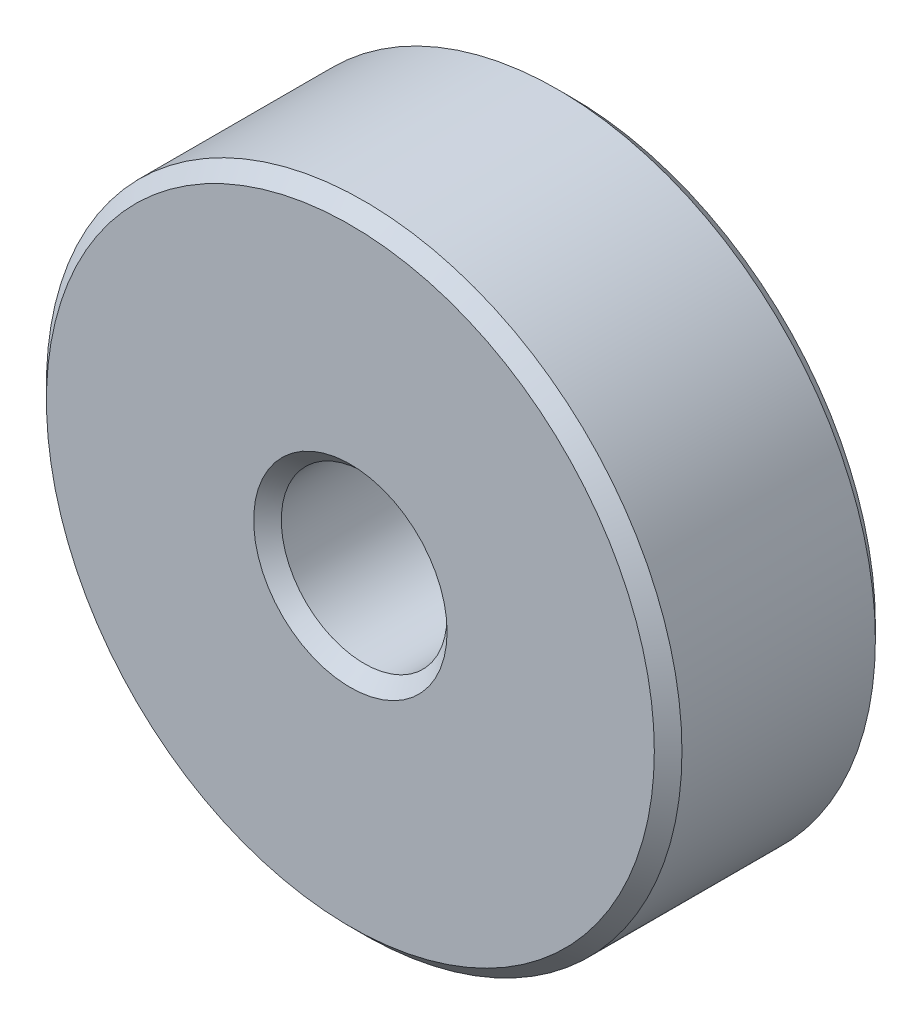
from build123d import *

# Parameters (mm, degrees)
SKETCH1_R           = 5.75
SKETCH1_R_2         = 1.5
BOSS_EXTRUDE1_DEPTH = 2
CHAMFER1_SIZE       = 0.25


with BuildPart() as part:
    # Sketch1 → Boss-Extrude1 (new body, symmetric)
    with BuildSketch(Plane.XY):
        Circle(SKETCH1_R)
        Circle(SKETCH1_R_2, mode=Mode.SUBTRACT)
    extrude(amount=BOSS_EXTRUDE1_DEPTH, both=True)

    # Chamfer1
    chamfer1_edges = [part.edges().sort_by_distance(p)[0] for p in [
        (-5.75, 0, -2),
        (-5.75, 0, 2),
        (-1.5, 0, -2),
        (-1.5, 0, 2),
    ]]
    chamfer(chamfer1_edges, length=CHAMFER1_SIZE)


solid = part.part
